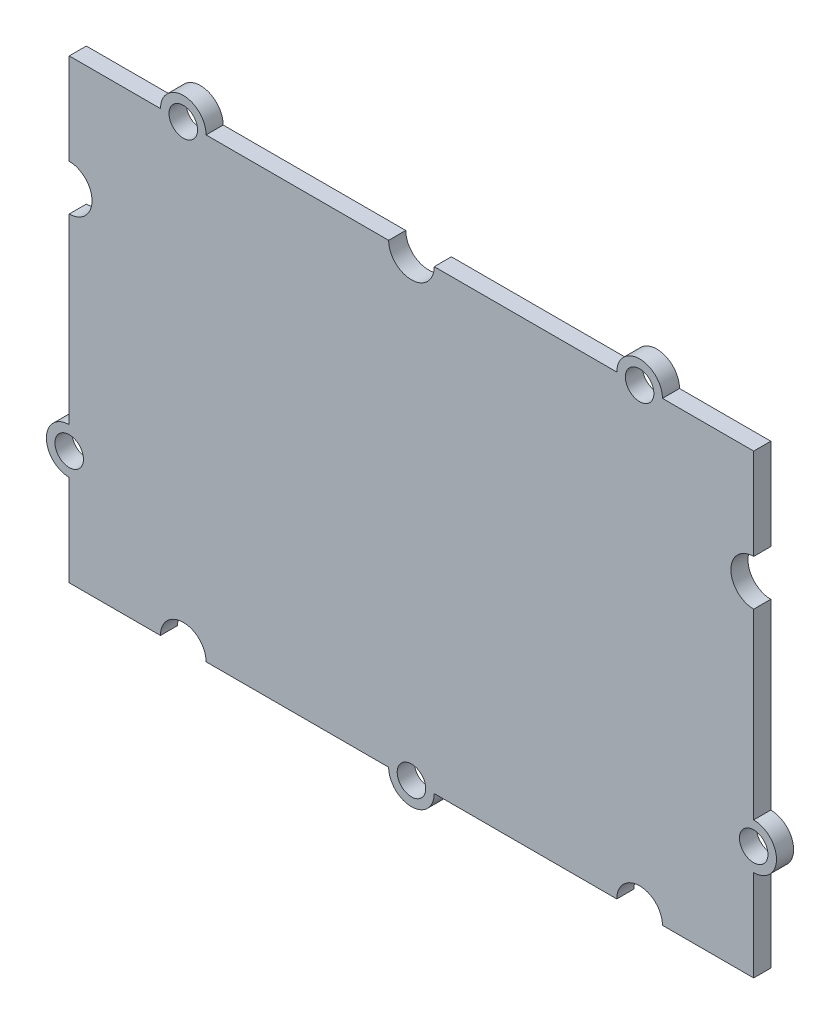
from build123d import *

# Parameters (mm, degrees)
ESQUISSE1_R        = 1.25
BOSS_EXTRU_1_DEPTH = 1.5


with BuildPart() as part:
    # Esquisse1 → Boss.-Extru.1 (new body)
    with BuildSketch(Plane.XY):
        with BuildLine():
            Line((-30, 20), (-22, 20))
            ThreePointArc((-22, 20), (-20, 22), (-18, 20))
            Line((-18, 20), (-2, 20))
            ThreePointArc((-2, 20), (0, 18), (2, 20))
            Line((2, 20), (18, 20))
            ThreePointArc((18, 20), (20, 22), (22, 20))
            Line((22, 20), (30, 20))
            Line((30, 20), (30, 12))
            ThreePointArc((30, 12), (28, 10), (30, 8))
            Line((30, 8), (30, -8))
            ThreePointArc((30, -8), (32, -10), (30, -12))
            Line((30, -12), (30, -20))
            Line((30, -20), (22, -20))
            ThreePointArc((22, -20), (20, -18), (18, -20))
            Line((18, -20), (2, -20))
            ThreePointArc((2, -20), (0, -22), (-2, -20))
            Line((-2, -20), (-18, -20))
            ThreePointArc((-18, -20), (-20, -18), (-22, -20))
            Line((-22, -20), (-30, -20))
            Line((-30, -20), (-30, -12))
            ThreePointArc((-30, -12), (-32, -10), (-30, -8))
            Line((-30, -8), (-30, 8))
            ThreePointArc((-30, 8), (-28, 10), (-30, 12))
            Line((-30, 12), (-30, 20))
        make_face()
        with Locations((-20, 20)):
            Circle(ESQUISSE1_R, mode=Mode.SUBTRACT)
        with Locations((20, 20)):
            Circle(ESQUISSE1_R, mode=Mode.SUBTRACT)
        with Locations((30, -10)):
            Circle(ESQUISSE1_R, mode=Mode.SUBTRACT)
        with Locations((0, -20)):
            Circle(ESQUISSE1_R, mode=Mode.SUBTRACT)
        with Locations((-30, -10)):
            Circle(ESQUISSE1_R, mode=Mode.SUBTRACT)
    extrude(amount=BOSS_EXTRU_1_DEPTH)


solid = part.part
